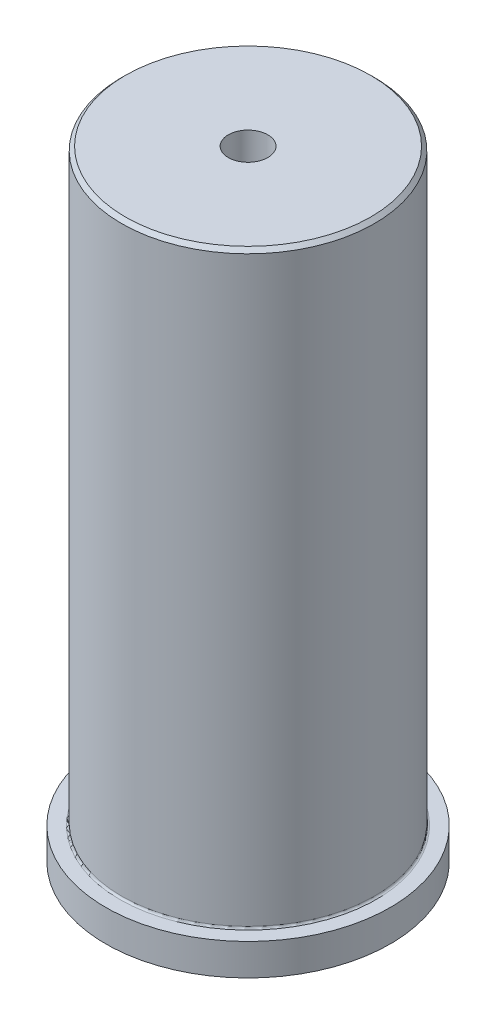
from build123d import *

# Parameters (mm, degrees)
F_3_8_16_TAPPED_HOLE1_D     = 7.9375
F_3_8_16_TAPPED_HOLE1_DEPTH = 29.5402
F_3_8_16_TAPPED_HOLE1_TIP   = 2.384665582
CHAMFER1_SIZE               = 0.762
FILLET1_R                   = 0.381
SKETCH4_R                   = 1.5875
CUT_EXTRUDE1_DEPTH          = 27.94


with BuildPart() as part:
    # Sketch1 → Revolve1 (revolve)
    with BuildSketch(Plane.XY, mode=Mode.PRIVATE) as revolve1_sk:
        Polygon((0, 0), (28.575, 0), (28.575, 6.35), (25.4, 6.35), (25.4, 124.46), (0, 124.46), align=None)
    revolve(revolve1_sk.sketch.rotate(Axis((0, 0, 0), (0, 1, 0)), 90), axis=Axis((0, 0, 0), (0, 1, 0)))  # turned: the seam where the file's is

    # 3/8-16 Tapped Hole1
    with Locations(Plane.ZX.offset(124.46)):
        with Locations((0, 0)):
            Hole(F_3_8_16_TAPPED_HOLE1_D / 2, depth=F_3_8_16_TAPPED_HOLE1_DEPTH)
            with Locations((0, 0, -(F_3_8_16_TAPPED_HOLE1_DEPTH + F_3_8_16_TAPPED_HOLE1_TIP / 2))):  # 118° drill point
                Cone(0, F_3_8_16_TAPPED_HOLE1_D / 2, F_3_8_16_TAPPED_HOLE1_TIP, mode=Mode.SUBTRACT)

    # Chamfer1
    chamfer1_edges = [part.edges().sort_by_distance(p)[0] for p in [
        (0, 124.46, 25.4),
    ]]
    chamfer(chamfer1_edges, length=CHAMFER1_SIZE)

    # Fillet1
    fillet1_edges = [part.edges().sort_by_distance(p)[0] for p in [
        (0, 6.35, 25.4),
    ]]
    fillet(fillet1_edges, radius=FILLET1_R)

    # Sketch4 → Cut-Extrude1 (cut)
    with BuildSketch(Plane.XY):
        with Locations((0, 94.9198)):
            Circle(SKETCH4_R)
    extrude(amount=-CUT_EXTRUDE1_DEPTH, mode=Mode.SUBTRACT)


solid = part.part
